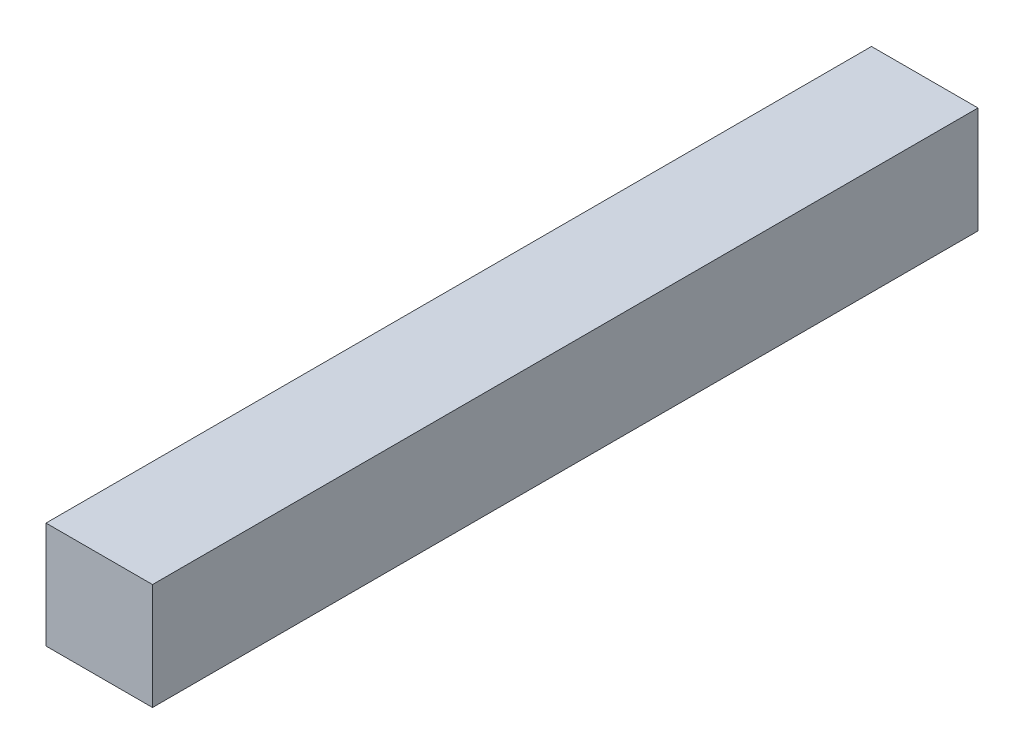
from build123d import *

# Parameters (mm, degrees)
SKETCH1_W           = 25.4
SKETCH1_H           = 25.4
BOSS_EXTRUDE1_DEPTH = 196.85


with BuildPart() as part:
    # Sketch1 → Boss-Extrude1 (new body)
    with BuildSketch(Plane.XY):
        with Locations((12.7, 12.7)):
            Rectangle(SKETCH1_W, SKETCH1_H)
    extrude(amount=BOSS_EXTRUDE1_DEPTH)


solid = part.part
